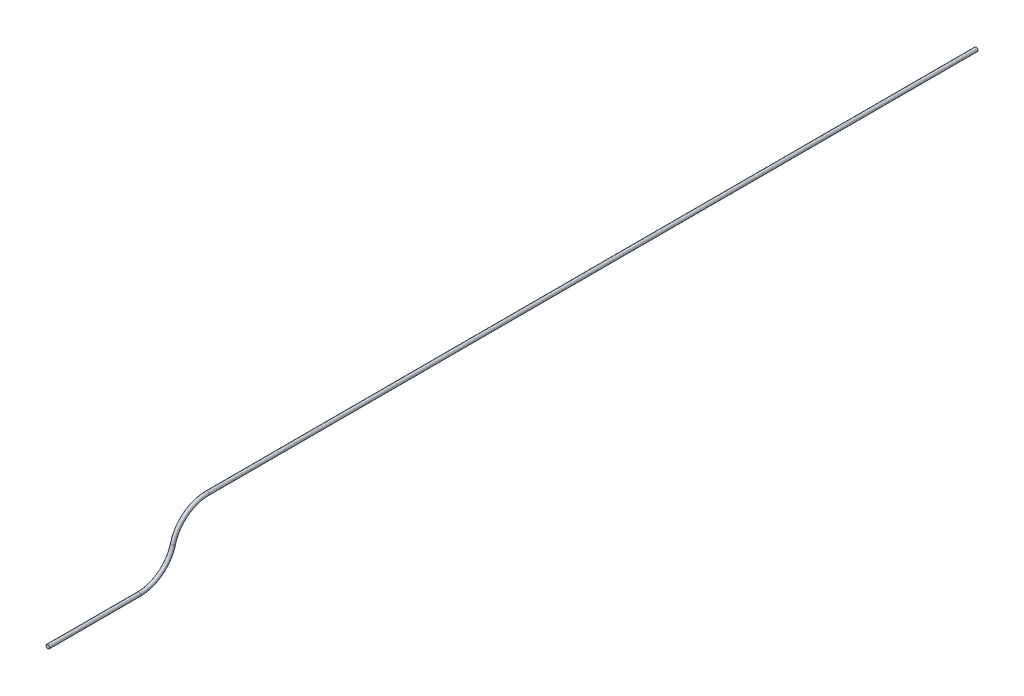
from build123d import *

# Parameters (mm, degrees)
SKETCH1_R = 4.03225


with BuildPart() as part:
    # Sweep1: sweep along a path in Sketch2
    with BuildLine(Plane(origin=(0, 0, 0), x_dir=(0, 0, -1), z_dir=(1, 0, 0))) as sweep1_path:
        Line((0, 0), (195, 0))
        ThreePointArc((195, 0), (241.6627796, 15.958610574), (268.780332745, 57.15))
        ThreePointArc((268.780332745, 57.15), (295.89788589, 98.341389426), (342.560665491, 114.3))
        Line((342.560665491, 114.3), (1993.560665491, 114.3))
    # Sketch1 → Sweep1 (sweep)
    with BuildSketch(Plane.XY):
        Circle(SKETCH1_R)
    sweep(path=sweep1_path.line)


solid = part.part
